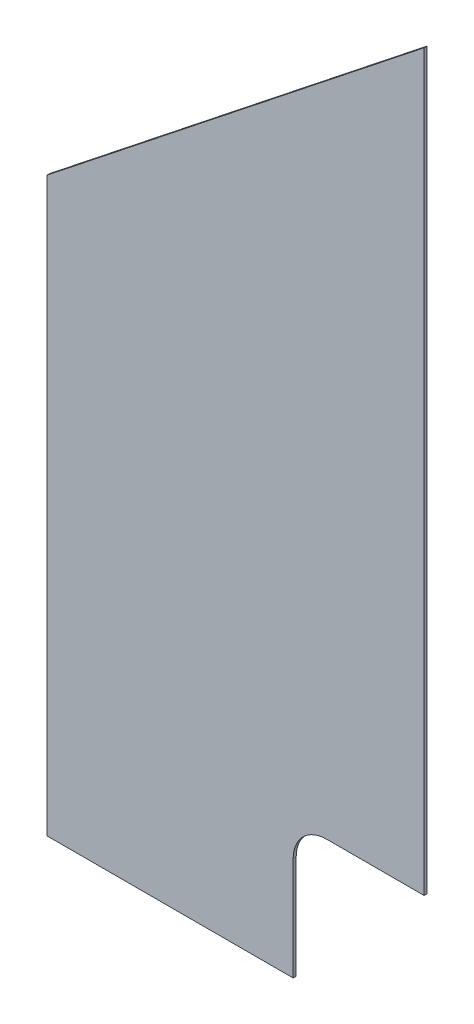
from build123d import *

# Parameters (mm, degrees)
BOSS_EXTRUDE1_DEPTH = 3.175
CUT_EXTRUDE3_DEPTH  = 4.175


with BuildPart() as part:
    # Sketch1 → Boss-Extrude1 (new body)
    with BuildSketch(Plane.XY):
        Polygon((0, 0), (-393.7, 0), (-393.7, 596.9), (0, 908.942774901), align=None)
    extrude(amount=BOSS_EXTRUDE1_DEPTH)

    # Sketch4 → Cut-Extrude3 (cut, through all)
    with BuildSketch(Plane.XY.offset(3.175)):
        with BuildLine():
            Line((0, 0), (-136.652, 0))
            Line((-136.652, 0), (-136.652, 107.95))
            ThreePointArc((-136.652, 107.95), (-126.422704333, 132.645704333), (-101.727, 142.875))
            Line((-101.727, 142.875), (0, 142.875))
            Line((0, 142.875), (0, 0))
        make_face()
    extrude(amount=-CUT_EXTRUDE3_DEPTH, mode=Mode.SUBTRACT)


solid = part.part
